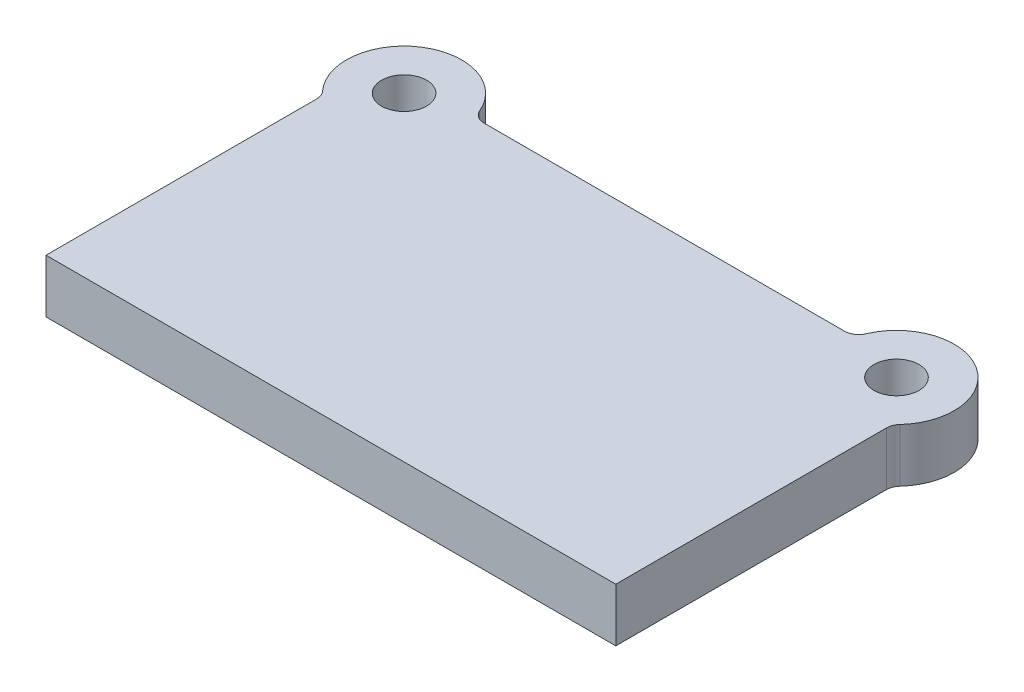
from build123d import *

# Parameters (mm, degrees)
SKETCH1_R           = 16
BOSS_EXTRUDE1_DEPTH = 38
FILLET1_R           = 10


with BuildPart() as part:
    # Sketch1 → Boss-Extrude1 (new body)
    with BuildSketch(Plane(origin=(0, 0, 0), x_dir=(1, 0, 0), z_dir=(0, 1, 0))):
        with BuildLine():
            Line((202.5, 0), (-202.5, 0))
            Line((-202.5, 0), (-202.5, 196.590297601))
            ThreePointArc((-202.5, 196.590297601), (-196.114542141, 262.145072346), (-135.238209296, 237))
            Line((-135.238209296, 237), (135.238209296, 237))
            ThreePointArc((135.238209296, 237), (196.114542141, 262.145072346), (202.5, 196.590297601))
            Line((202.5, 196.590297601), (202.5, 0))
        make_face()
        with Locations((-175, 227)):
            Circle(SKETCH1_R, mode=Mode.SUBTRACT)
        with Locations((175, 227)):
            Circle(SKETCH1_R, mode=Mode.SUBTRACT)
    extrude(amount=BOSS_EXTRUDE1_DEPTH)

    # Fillet1
    fillet1_edges = [part.edges().sort_by_distance(p)[0] for p in [
        (-202.5, 19, -196.590297601),
        (-135.238209296, 19, -237),
        (135.238209296, 19, -237),
        (202.5, 19, -196.590297601),
    ]]
    fillet(fillet1_edges, radius=FILLET1_R)


solid = part.part
